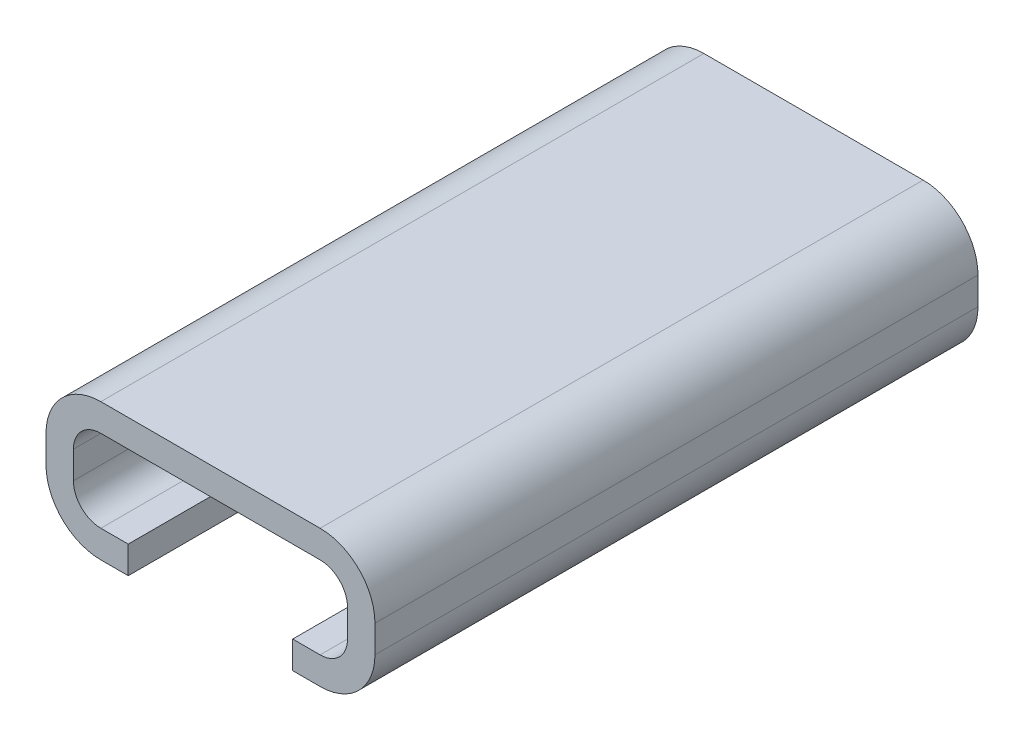
from build123d import *

# Parameters (mm, degrees)
BOSS_EXTRU_2_DEPTH      = 10
BOSS_EXTRU_4_DEPTH      = 1
ESQUISSE5_W             = 6
ESQUISSE5_H             = 10
ENL_V_MAT_EXTRU_1_DEPTH = 1


with BuildPart() as part:
    # Esquisse1 → Boss.-Extru.2 (new body)
    with BuildSketch(Plane.XY):
        with BuildLine():
            Line((6, -0.5), (6, 0.5))
            ThreePointArc((6, 0.5), (5.414213562, 1.914213562), (4, 2.5))
            Line((4, 2.5), (-2.232050808, 2.5))
            Line((-2.232050808, 2.5), (-4, 2.5))
            ThreePointArc((-4, 2.5), (-5.414213562, 1.914213562), (-6, 0.5))
            Line((-6, 0.5), (-6, -0.5))
            ThreePointArc((-6, -0.5), (-5.414213562, -1.914213562), (-4, -2.5))
            Line((-4, -2.5), (4, -2.5))
            ThreePointArc((4, -2.5), (5.414213562, -1.914213562), (6, -0.5))
        make_face()
        with BuildLine():
            ThreePointArc((4, 1.5), (4.707106781, 1.207106781), (5, 0.5))
            Line((5, 0.5), (5, -0.5))
            ThreePointArc((5, -0.5), (4.707106781, -1.207106781), (4, -1.5))
            Line((4, -1.5), (-4, -1.5))
            ThreePointArc((-4, -1.5), (-4.707106781, -1.207106781), (-5, -0.5))
            Line((-5, -0.5), (-5, 0.5))
            ThreePointArc((-5, 0.5), (-4.707106781, 1.207106781), (-4, 1.5))
            Line((-4, 1.5), (4, 1.5))
        make_face(mode=Mode.SUBTRACT)
    boss_extru_2 = extrude(amount=BOSS_EXTRU_2_DEPTH)

    # Esquisse7 → Boss.-Extru.4 (add)
    with BuildSketch(Plane(origin=(0, 0, 0), x_dir=(-1, 0, 0), z_dir=(0, 0, -1))):
        with BuildLine():
            Line((-6, 0.5), (-6, -0.5))
            ThreePointArc((-6, -0.5), (-5.414213562, -1.914213562), (-4, -2.5))
            Line((-4, -2.5), (4, -2.5))
            ThreePointArc((4, -2.5), (5.414213562, -1.914213562), (6, -0.5))
            Line((6, -0.5), (6, 0.5))
            ThreePointArc((6, 0.5), (5.414213562, 1.914213562), (4, 2.5))
            Line((4, 2.5), (-4, 2.5))
            ThreePointArc((-4, 2.5), (-5.414213562, 1.914213562), (-6, 0.5))
        make_face()
    boss_extru_4 = extrude(amount=BOSS_EXTRU_4_DEPTH)

    # Symétrie1: Boss.-Extru.2, Boss.-Extru.4 across plane
    add(boss_extru_2.mirror(Plane(origin=(4, 0.5, -1), x_dir=(1, 0, 0), z_dir=(0, 0, -1))))
    add(boss_extru_4.mirror(Plane(origin=(4, 0.5, -1), x_dir=(1, 0, 0), z_dir=(0, 0, -1))))

    # Esquisse5 → Enlèv. mat.-Extru.1 (cut)
    with BuildSketch(Plane.XZ.offset(2.5)):
        with Locations((0, -7)):
            Rectangle(ESQUISSE5_W, ESQUISSE5_H)
        with Locations((0, 5)):
            Rectangle(ESQUISSE5_W, ESQUISSE5_H)
    extrude(amount=-ENL_V_MAT_EXTRU_1_DEPTH, mode=Mode.SUBTRACT)


solid = part.part
